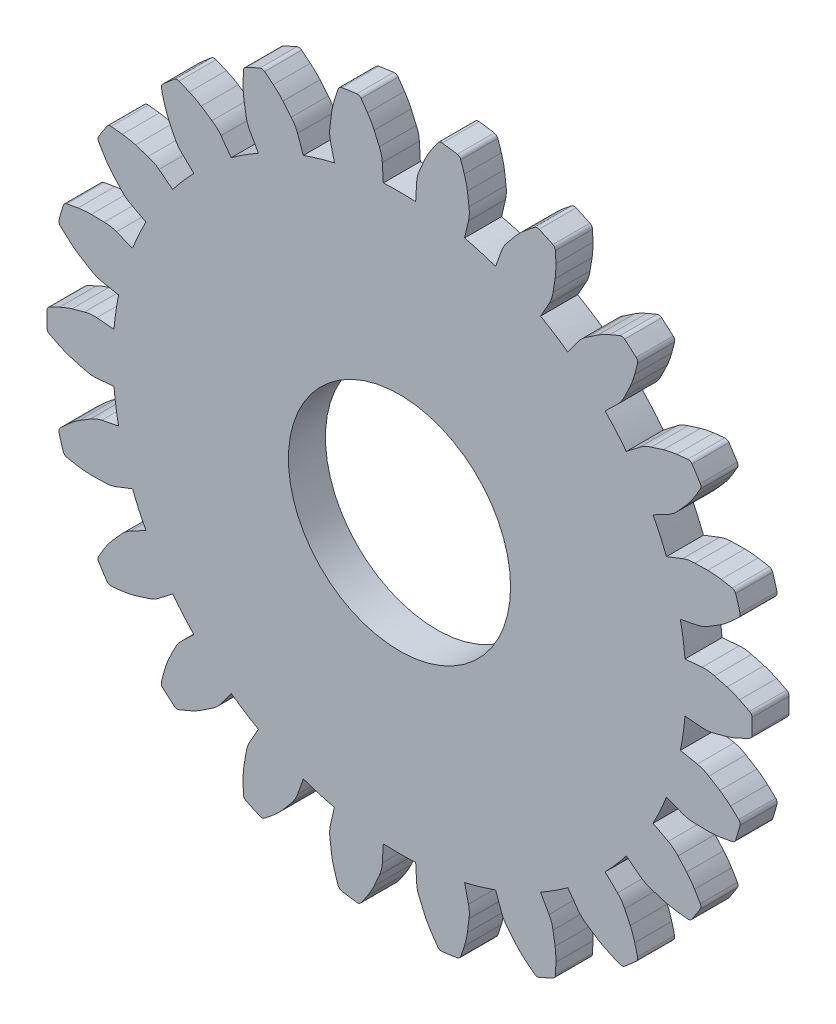
from build123d import *

# Parameters (mm, degrees)
MODEL_R             = 6
BOSS_EXTRUDE1_DEPTH = 2


with BuildPart() as part:
    # Model → Boss-Extrude1 (new body)
    with BuildSketch(Plane.XY):
        with BuildLine():
            Line((38.30992667, 23.504889052), (39.237718015, 23.585160756))
            ThreePointArc((39.237718015, 23.585160756), (39.575191224, 23.582048709), (39.905936677, 23.514927199))
            ThreePointArc((39.905936677, 23.514927199), (40.243502274, 23.423304664), (40.581052968, 23.331627241))
            ThreePointArc((40.581052968, 23.331627241), (40.924312438, 23.212321267), (41.257400116, 23.067016148))
            ThreePointArc((41.257400116, 23.067016148), (41.528774658, 22.934370847), (41.798724995, 22.798850613))
            ThreePointArc((41.798724995, 22.798850613), (41.896818886, 22.70924055), (41.934970041, 22.581973648))
            ThreePointArc((41.934970041, 22.581973648), (41.938299731, 22.376358445), (41.93940967, 22.170719278))
            ThreePointArc((41.93940967, 22.170719278), (41.938299731, 21.965080111), (41.934970041, 21.759464907))
            ThreePointArc((41.934970041, 21.759464907), (41.896818886, 21.632198005), (41.798724995, 21.542587942))
            ThreePointArc((41.798724995, 21.542587942), (41.528774658, 21.407067708), (41.257400116, 21.274422407))
            ThreePointArc((41.257400116, 21.274422407), (40.924312438, 21.129117288), (40.581052968, 21.009811315))
            ThreePointArc((40.581052968, 21.009811315), (40.243502274, 20.918133892), (39.905936677, 20.826511357))
            ThreePointArc((39.905936677, 20.826511357), (39.575191224, 20.759389846), (39.237718015, 20.756277799))
            Line((39.237718015, 20.756277799), (38.30992667, 20.836549503))
            ThreePointArc((38.30992667, 20.836549503), (38.266092553, 20.401545167), (38.209989675, 19.967952421))
            ThreePointArc((38.209989675, 19.967952421), (38.141662799, 19.536117221), (38.061166442, 19.10638412))
            Line((38.061166442, 19.10638412), (38.973990872, 18.922015227))
            ThreePointArc((38.973990872, 18.922015227), (39.29691728, 18.82395205), (39.595354903, 18.666367671))
            ThreePointArc((39.595354903, 18.666367671), (39.89343367, 18.483353273), (40.191482675, 18.30029041))
            ThreePointArc((40.191482675, 18.30029041), (40.487225347, 18.089109799), (40.765883452, 17.855848915))
            ThreePointArc((40.765883452, 17.855848915), (40.988894918, 17.652121637), (41.209729907, 17.446037126))
            ThreePointArc((41.209729907, 17.446037126), (41.278604235, 17.332420657), (41.27935477, 17.199560537))
            ThreePointArc((41.27935477, 17.199560537), (41.224621087, 17.001336112), (41.167750818, 16.80371407))
            ThreePointArc((41.167750818, 16.80371407), (41.10875059, 16.60671744), (41.047627279, 16.410369179))
            ThreePointArc((41.047627279, 16.410369179), (40.975166285, 16.299005903), (40.855799813, 16.24066192))
            ThreePointArc((40.855799813, 16.24066192), (40.5586039, 16.186685006), (40.260851433, 16.135867815))
            ThreePointArc((40.260851433, 16.135867815), (39.900318964, 16.090290218), (39.537351537, 16.072524343))
            ThreePointArc((39.537351537, 16.072524343), (39.187645504, 16.07965952), (38.837940634, 16.08685156))
            ThreePointArc((38.837940634, 16.08685156), (38.501682381, 16.115630705), (38.177002443, 16.207721908))
            Line((38.177002443, 16.207721908), (37.309408319, 16.546131071))
            ThreePointArc((37.309408319, 16.546131071), (37.144794908, 16.141096965), (36.968807398, 15.74087378))
            ThreePointArc((36.968807398, 15.74087378), (36.781586206, 15.345780845), (36.583280712, 14.956133398))
            Line((36.583280712, 14.956133398), (37.407186618, 14.52206038))
            ThreePointArc((37.407186618, 14.52206038), (37.689404648, 14.336990568), (37.931356801, 14.101709869))
            ThreePointArc((37.931356801, 14.101709869), (38.165800169, 13.842130347), (38.400201326, 13.582512708))
            ThreePointArc((38.400201326, 13.582512708), (38.624467889, 13.296566056), (38.826121197, 12.994246817))
            ThreePointArc((38.826121197, 12.994246817), (38.982702525, 12.735942334), (39.136531429, 12.475989288))
            ThreePointArc((39.136531429, 12.475989288), (39.170606404, 12.347570944), (39.133895516, 12.219881142))
            ThreePointArc((39.133895516, 12.219881142), (39.025532657, 12.045106459), (38.915289471, 11.871511705))
            ThreePointArc((38.915289471, 11.871511705), (38.803178803, 11.699117108), (38.689213718, 11.527942757))
            ThreePointArc((38.689213718, 11.527942757), (38.588313242, 11.441505098), (38.457344552, 11.419153878))
            ThreePointArc((38.457344552, 11.419153878), (38.156980107, 11.451093173), (37.856971851, 11.486220999))
            ThreePointArc((37.856971851, 11.486220999), (37.498202787, 11.544063349), (37.144932866, 11.629276858))
            ThreePointArc((37.144932866, 11.629276858), (36.811402595, 11.734646585), (36.477889462, 11.840070544))
            ThreePointArc((36.477889462, 11.840070544), (36.163360053, 11.962418828), (35.877777024, 12.142252599))
            Line((35.877777024, 12.142252599), (35.140667436, 12.711383325))
            ThreePointArc((35.140667436, 12.711383325), (34.868610731, 12.369132903), (34.586996051, 12.03470298))
            ThreePointArc((34.586996051, 12.03470298), (34.296048089, 11.70836039), (33.995998989, 11.390365517))
            Line((33.995998989, 11.390365517), (34.664238417, 10.741754389))
            ThreePointArc((34.664238417, 10.741754389), (34.882884442, 10.484671197), (35.048749599, 10.190755221))
            ThreePointArc((35.048749599, 10.190755221), (35.200564362, 9.875640164), (35.352327884, 9.560500426))
            ThreePointArc((35.352327884, 9.560500426), (35.486949594, 9.222953431), (35.595261353, 8.876067943))
            ThreePointArc((35.595261353, 8.876067943), (35.672727255, 8.584112549), (35.747087772, 8.291350817))
            ThreePointArc((35.747087772, 8.291350817), (35.743602842, 8.158534289), (35.672404629, 8.046359473))
            ThreePointArc((35.672404629, 8.046359473), (35.519191509, 7.909193738), (35.364506652, 7.773689886))
            ThreePointArc((35.364506652, 7.773689886), (35.208368083, 7.639863707), (35.050793997, 7.507730795))
            ThreePointArc((35.050793997, 7.507730795), (34.929628397, 7.453221417), (34.797667793, 7.468673722))
            ThreePointArc((34.797667793, 7.468673722), (34.518468558, 7.583941694), (34.240509396, 7.70216869))
            ThreePointArc((34.240509396, 7.70216869), (33.912569073, 7.858744944), (33.597616486, 8.040034345))
            ThreePointArc((33.597616486, 8.040034345), (33.307282617, 8.235102194), (33.016980471, 8.430217249))
            ThreePointArc((33.016980471, 8.430217249), (32.749661208, 8.636222743), (32.526311327, 8.88923002))
            Line((32.526311327, 8.88923002), (31.979402511, 9.642974721))
            ThreePointArc((31.979402511, 9.642974721), (31.621942928, 9.391235077), (31.257515823, 9.14969194))
            ThreePointArc((31.257515823, 9.14969194), (30.886411966, 8.918538031), (30.508927454, 8.697957784))
            Line((30.508927454, 8.697957784), (30.967363618, 7.887355162))
            ThreePointArc((30.967363618, 7.887355162), (31.104724238, 7.579085942), (31.181064992, 7.250346013))
            ThreePointArc((31.181064992, 7.250346013), (31.237952019, 6.905224169), (31.294782928, 6.56009308))
            ThreePointArc((31.294782928, 6.56009308), (31.328853534, 6.198291791), (31.335048971, 5.834942654))
            ThreePointArc((31.335048971, 5.834942654), (31.32712362, 5.532988838), (31.315991502, 5.231136235))
            ThreePointArc((31.315991502, 5.231136235), (31.275228996, 5.104681527), (31.175311513, 5.017109435))
            ThreePointArc((31.175311513, 5.017109435), (30.989660548, 4.928665), (30.803065668, 4.842229766))
            ThreePointArc((30.803065668, 4.842229766), (30.615548617, 4.757813806), (30.427131245, 4.675426955))
            ThreePointArc((30.427131245, 4.675426955), (30.295516637, 4.657261884), (30.173254782, 4.709265861))
            ThreePointArc((30.173254782, 4.709265861), (29.937839818, 4.898524185), (29.704448349, 5.090272301))
            ThreePointArc((29.704448349, 5.090272301), (29.433904542, 5.332897583), (29.182784874, 5.595575887))
            ThreePointArc((29.182784874, 5.595575887), (28.959168531, 5.86453862), (28.735595925, 6.133537711))
            ThreePointArc((28.735595925, 6.133537711), (28.537143425, 6.406511074), (28.39412117, 6.712194712))
            Line((28.39412117, 6.712194712), (28.081720426, 7.589489476))
            ThreePointArc((28.081720426, 7.589489476), (27.667817214, 7.448655059), (27.250101402, 7.319567095))
            ThreePointArc((27.250101402, 7.319567095), (26.828906277, 7.202328582), (26.404567903, 7.097033062))
            Line((26.404567903, 7.097033062), (26.616061032, 6.19010915))
            ThreePointArc((26.616061032, 6.19010915), (26.661008106, 5.85562804), (26.641639782, 5.518696712))
            ThreePointArc((26.641639782, 5.518696712), (26.598990425, 5.171527801), (26.556284619, 4.824365828))
            ThreePointArc((26.556284619, 4.824365828), (26.487043924, 4.467621235), (26.390621121, 4.117244834))
            ThreePointArc((26.390621121, 4.117244834), (26.297946582, 3.829755099), (26.202223687, 3.543265927))
            ThreePointArc((26.202223687, 3.543265927), (26.127485941, 3.433417649), (26.006943908, 3.377542849))
            ThreePointArc((26.006943908, 3.377542849), (25.803895435, 3.344984957), (25.600507339, 3.31462081))
            ThreePointArc((25.600507339, 3.31462081), (25.396803322, 3.286453947), (25.19280712, 3.260487651))
            ThreePointArc((25.19280712, 3.260487651), (25.061406136, 3.280138513), (24.958747958, 3.364481108))
            ThreePointArc((24.958747958, 3.364481108), (24.786189186, 3.6123972), (24.616273399, 3.862132146))
            ThreePointArc((24.616273399, 3.862132146), (24.425043957, 4.171150397), (24.258101431, 4.49393697))
            ThreePointArc((24.258101431, 4.49393697), (24.11931868, 4.815004827), (23.980588137, 5.136095247))
            ThreePointArc((23.980588137, 5.136095247), (23.867079841, 5.453921801), (23.815972025, 5.787517129))
            Line((23.815972025, 5.787517129), (23.763388203, 6.717288751))
            ThreePointArc((23.763388203, 6.717288751), (23.326573339, 6.698769128), (22.88940967, 6.692594278))
            ThreePointArc((22.88940967, 6.692594278), (22.452246001, 6.698769128), (22.015431137, 6.717288751))
            Line((22.015431137, 6.717288751), (21.962847315, 5.787517129))
            ThreePointArc((21.962847315, 5.787517129), (21.911739499, 5.453921801), (21.798231204, 5.136095247))
            ThreePointArc((21.798231204, 5.136095247), (21.659500661, 4.815004827), (21.520717909, 4.49393697))
            ThreePointArc((21.520717909, 4.49393697), (21.353775383, 4.171150397), (21.162545942, 3.862132146))
            ThreePointArc((21.162545942, 3.862132146), (20.992630154, 3.6123972), (20.820071382, 3.364481108))
            ThreePointArc((20.820071382, 3.364481108), (20.717413204, 3.280138513), (20.58601222, 3.260487651))
            ThreePointArc((20.58601222, 3.260487651), (20.382016019, 3.286453947), (20.178312001, 3.31462081))
            ThreePointArc((20.178312001, 3.31462081), (19.974923905, 3.344984957), (19.771875432, 3.377542849))
            ThreePointArc((19.771875432, 3.377542849), (19.651333399, 3.433417649), (19.576595654, 3.543265927))
            ThreePointArc((19.576595654, 3.543265927), (19.480872759, 3.829755099), (19.388198219, 4.117244834))
            ThreePointArc((19.388198219, 4.117244834), (19.291775416, 4.467621235), (19.222534722, 4.824365828))
            ThreePointArc((19.222534722, 4.824365828), (19.179828915, 5.171527801), (19.137179558, 5.518696712))
            ThreePointArc((19.137179558, 5.518696712), (19.117811234, 5.85562804), (19.162758309, 6.19010915))
            Line((19.162758309, 6.19010915), (19.374251437, 7.097033062))
            ThreePointArc((19.374251437, 7.097033062), (18.949913064, 7.202328582), (18.528717939, 7.319567095))
            ThreePointArc((18.528717939, 7.319567095), (18.111002127, 7.448655059), (17.697098915, 7.589489476))
            Line((17.697098915, 7.589489476), (17.384698171, 6.712194712))
            ThreePointArc((17.384698171, 6.712194712), (17.241675916, 6.406511074), (17.043223416, 6.133537711))
            ThreePointArc((17.043223416, 6.133537711), (16.819650809, 5.86453862), (16.596034466, 5.595575887))
            ThreePointArc((16.596034466, 5.595575887), (16.344914799, 5.332897583), (16.074370991, 5.090272301))
            ThreePointArc((16.074370991, 5.090272301), (15.840979522, 4.898524185), (15.605564559, 4.709265861))
            ThreePointArc((15.605564559, 4.709265861), (15.483302703, 4.657261884), (15.351688095, 4.675426955))
            ThreePointArc((15.351688095, 4.675426955), (15.163270724, 4.757813806), (14.975753672, 4.842229766))
            ThreePointArc((14.975753672, 4.842229766), (14.789158792, 4.928665), (14.603507827, 5.017109435))
            ThreePointArc((14.603507827, 5.017109435), (14.503590344, 5.104681527), (14.462827838, 5.231136235))
            ThreePointArc((14.462827838, 5.231136235), (14.45169572, 5.532988838), (14.443770369, 5.834942654))
            ThreePointArc((14.443770369, 5.834942654), (14.449965806, 6.198291791), (14.484036413, 6.56009308))
            ThreePointArc((14.484036413, 6.56009308), (14.540867322, 6.905224169), (14.597754349, 7.250346013))
            ThreePointArc((14.597754349, 7.250346013), (14.674095102, 7.579085942), (14.811455722, 7.887355162))
            Line((14.811455722, 7.887355162), (15.269891886, 8.697957784))
            ThreePointArc((15.269891886, 8.697957784), (14.892407374, 8.918538031), (14.521303517, 9.14969194))
            ThreePointArc((14.521303517, 9.14969194), (14.156876413, 9.391235077), (13.799416829, 9.642974721))
            Line((13.799416829, 9.642974721), (13.252508014, 8.88923002))
            ThreePointArc((13.252508014, 8.88923002), (13.029158132, 8.636222743), (12.761838869, 8.430217249))
            ThreePointArc((12.761838869, 8.430217249), (12.471536723, 8.235102194), (12.181202854, 8.040034345))
            ThreePointArc((12.181202854, 8.040034345), (11.866250267, 7.858744944), (11.538309944, 7.70216869))
            ThreePointArc((11.538309944, 7.70216869), (11.260350782, 7.583941694), (10.981151548, 7.468673722))
            ThreePointArc((10.981151548, 7.468673722), (10.849190943, 7.453221417), (10.728025343, 7.507730795))
            ThreePointArc((10.728025343, 7.507730795), (10.570451257, 7.639863707), (10.414312688, 7.773689886))
            ThreePointArc((10.414312688, 7.773689886), (10.259627832, 7.909193738), (10.106414712, 8.046359473))
            ThreePointArc((10.106414712, 8.046359473), (10.035216498, 8.158534289), (10.031731569, 8.291350817))
            ThreePointArc((10.031731569, 8.291350817), (10.106092085, 8.584112549), (10.183557987, 8.876067943))
            ThreePointArc((10.183557987, 8.876067943), (10.291869747, 9.222953431), (10.426491456, 9.560500426))
            ThreePointArc((10.426491456, 9.560500426), (10.578254978, 9.875640164), (10.730069741, 10.190755221))
            ThreePointArc((10.730069741, 10.190755221), (10.895934898, 10.484671197), (11.114580924, 10.741754389))
            Line((11.114580924, 10.741754389), (11.782820351, 11.390365517))
            ThreePointArc((11.782820351, 11.390365517), (11.482771251, 11.70836039), (11.19182329, 12.03470298))
            ThreePointArc((11.19182329, 12.03470298), (10.910208609, 12.369132903), (10.638151904, 12.711383325))
            Line((10.638151904, 12.711383325), (9.901042316, 12.142252599))
            ThreePointArc((9.901042316, 12.142252599), (9.615459287, 11.962418828), (9.300929878, 11.840070544))
            ThreePointArc((9.300929878, 11.840070544), (8.967416745, 11.734646585), (8.633886474, 11.629276858))
            ThreePointArc((8.633886474, 11.629276858), (8.280616554, 11.544063349), (7.921847489, 11.486220999))
            ThreePointArc((7.921847489, 11.486220999), (7.621839233, 11.451093173), (7.321474788, 11.419153878))
            ThreePointArc((7.321474788, 11.419153878), (7.190506098, 11.441505098), (7.089605623, 11.527942757))
            ThreePointArc((7.089605623, 11.527942757), (6.975640538, 11.699117108), (6.86352987, 11.871511705))
            ThreePointArc((6.86352987, 11.871511705), (6.753286683, 12.045106459), (6.644923824, 12.219881142))
            ThreePointArc((6.644923824, 12.219881142), (6.608212936, 12.347570944), (6.642287911, 12.475989288))
            ThreePointArc((6.642287911, 12.475989288), (6.796116815, 12.735942334), (6.952698144, 12.994246817))
            ThreePointArc((6.952698144, 12.994246817), (7.154351451, 13.296566056), (7.378618014, 13.582512708))
            ThreePointArc((7.378618014, 13.582512708), (7.613019171, 13.842130347), (7.84746254, 14.101709869))
            ThreePointArc((7.84746254, 14.101709869), (8.089414692, 14.336990568), (8.371632722, 14.52206038))
            Line((8.371632722, 14.52206038), (9.195538629, 14.956133398))
            ThreePointArc((9.195538629, 14.956133398), (8.997233134, 15.345780845), (8.810011942, 15.74087378))
            ThreePointArc((8.810011942, 15.74087378), (8.634024432, 16.141096965), (8.469411022, 16.546131071))
            Line((8.469411022, 16.546131071), (7.601816897, 16.207721908))
            ThreePointArc((7.601816897, 16.207721908), (7.277136959, 16.115630705), (6.940878706, 16.08685156))
            ThreePointArc((6.940878706, 16.08685156), (6.591173837, 16.07965952), (6.241467803, 16.072524343))
            ThreePointArc((6.241467803, 16.072524343), (5.878500376, 16.090290218), (5.517967907, 16.135867815))
            ThreePointArc((5.517967907, 16.135867815), (5.220215441, 16.186685006), (4.923019527, 16.24066192))
            ThreePointArc((4.923019527, 16.24066192), (4.803653056, 16.299005903), (4.731192061, 16.410369179))
            ThreePointArc((4.731192061, 16.410369179), (4.67006875, 16.60671744), (4.611068523, 16.80371407))
            ThreePointArc((4.611068523, 16.80371407), (4.554198254, 17.001336112), (4.49946457, 17.199560537))
            ThreePointArc((4.49946457, 17.199560537), (4.500215106, 17.332420657), (4.569089433, 17.446037126))
            ThreePointArc((4.569089433, 17.446037126), (4.789924422, 17.652121637), (5.012935889, 17.855848915))
            ThreePointArc((5.012935889, 17.855848915), (5.291593993, 18.089109799), (5.587336665, 18.30029041))
            ThreePointArc((5.587336665, 18.30029041), (5.88538567, 18.483353273), (6.183464437, 18.666367671))
            ThreePointArc((6.183464437, 18.666367671), (6.48190206, 18.82395205), (6.804828469, 18.922015227))
            Line((6.804828469, 18.922015227), (7.717652898, 19.10638412))
            ThreePointArc((7.717652898, 19.10638412), (7.637156541, 19.536117221), (7.568829665, 19.967952421))
            ThreePointArc((7.568829665, 19.967952421), (7.512726787, 20.401545167), (7.468892671, 20.836549503))
            Line((7.468892671, 20.836549503), (6.541101325, 20.756277799))
            ThreePointArc((6.541101325, 20.756277799), (6.203628116, 20.759389846), (5.872882663, 20.826511357))
            ThreePointArc((5.872882663, 20.826511357), (5.535317066, 20.918133892), (5.197766372, 21.009811315))
            ThreePointArc((5.197766372, 21.009811315), (4.854506902, 21.129117288), (4.521419224, 21.274422407))
            ThreePointArc((4.521419224, 21.274422407), (4.250044682, 21.407067708), (3.980094345, 21.542587942))
            ThreePointArc((3.980094345, 21.542587942), (3.882000454, 21.632198005), (3.843849299, 21.759464907))
            ThreePointArc((3.843849299, 21.759464907), (3.84051961, 21.965080111), (3.83940967, 22.170719278))
            ThreePointArc((3.83940967, 22.170719278), (3.84051961, 22.376358445), (3.843849299, 22.581973648))
            ThreePointArc((3.843849299, 22.581973648), (3.882000454, 22.70924055), (3.980094345, 22.798850613))
            ThreePointArc((3.980094345, 22.798850613), (4.250044682, 22.934370847), (4.521419224, 23.067016148))
            ThreePointArc((4.521419224, 23.067016148), (4.854506902, 23.212321267), (5.197766372, 23.331627241))
            ThreePointArc((5.197766372, 23.331627241), (5.535317066, 23.423304664), (5.872882663, 23.514927199))
            ThreePointArc((5.872882663, 23.514927199), (6.203628116, 23.582048709), (6.541101325, 23.585160756))
            Line((6.541101325, 23.585160756), (7.468892671, 23.504889052))
            ThreePointArc((7.468892671, 23.504889052), (7.512726787, 23.939893388), (7.568829665, 24.373486134))
            ThreePointArc((7.568829665, 24.373486134), (7.637156541, 24.805321334), (7.717652898, 25.235054435))
            Line((7.717652898, 25.235054435), (6.804828469, 25.419423328))
            ThreePointArc((6.804828469, 25.419423328), (6.48190206, 25.517486505), (6.183464437, 25.675070885))
            ThreePointArc((6.183464437, 25.675070885), (5.88538567, 25.858085282), (5.587336665, 26.041148145))
            ThreePointArc((5.587336665, 26.041148145), (5.291593993, 26.252328756), (5.012935889, 26.48558964))
            ThreePointArc((5.012935889, 26.48558964), (4.789924422, 26.689316918), (4.569089433, 26.895401429))
            ThreePointArc((4.569089433, 26.895401429), (4.500215106, 27.009017898), (4.49946457, 27.141878018))
            ThreePointArc((4.49946457, 27.141878018), (4.554198254, 27.340102444), (4.611068523, 27.537724485))
            ThreePointArc((4.611068523, 27.537724485), (4.67006875, 27.734721115), (4.731192061, 27.931069377))
            ThreePointArc((4.731192061, 27.931069377), (4.803653056, 28.042432652), (4.923019527, 28.100776635))
            ThreePointArc((4.923019527, 28.100776635), (5.220215441, 28.154753549), (5.517967907, 28.20557074))
            ThreePointArc((5.517967907, 28.20557074), (5.878500376, 28.251148337), (6.241467803, 28.268914212))
            ThreePointArc((6.241467803, 28.268914212), (6.591173837, 28.261779035), (6.940878706, 28.254586995))
            ThreePointArc((6.940878706, 28.254586995), (7.277136959, 28.225807851), (7.601816897, 28.133716648))
            Line((7.601816897, 28.133716648), (8.469411022, 27.795307484))
            ThreePointArc((8.469411022, 27.795307484), (8.634024432, 28.20034159), (8.810011942, 28.600564776))
            ThreePointArc((8.810011942, 28.600564776), (8.997233134, 28.995657711), (9.195538629, 29.385305158))
            Line((9.195538629, 29.385305158), (8.371632722, 29.819378175))
            ThreePointArc((8.371632722, 29.819378175), (8.089414692, 30.004447987), (7.84746254, 30.239728687))
            ThreePointArc((7.84746254, 30.239728687), (7.613019171, 30.499308208), (7.378618014, 30.758925847))
            ThreePointArc((7.378618014, 30.758925847), (7.154351451, 31.044872499), (6.952698144, 31.347191738))
            ThreePointArc((6.952698144, 31.347191738), (6.796116815, 31.605496221), (6.642287911, 31.865449267))
            ThreePointArc((6.642287911, 31.865449267), (6.608212936, 31.993867611), (6.644923824, 32.121557413))
            ThreePointArc((6.644923824, 32.121557413), (6.753286683, 32.296332096), (6.86352987, 32.46992685))
            ThreePointArc((6.86352987, 32.46992685), (6.975640538, 32.642321447), (7.089605623, 32.813495798))
            ThreePointArc((7.089605623, 32.813495798), (7.190506098, 32.899933457), (7.321474788, 32.922284678))
            ThreePointArc((7.321474788, 32.922284678), (7.621839233, 32.890345383), (7.921847489, 32.855217556))
            ThreePointArc((7.921847489, 32.855217556), (8.280616554, 32.797375206), (8.633886474, 32.712161698))
            ThreePointArc((8.633886474, 32.712161698), (8.967416745, 32.60679197), (9.300929878, 32.501368012))
            ThreePointArc((9.300929878, 32.501368012), (9.615459287, 32.379019727), (9.901042316, 32.199185956))
            Line((9.901042316, 32.199185956), (10.638151904, 31.63005523))
            ThreePointArc((10.638151904, 31.63005523), (10.910208609, 31.972305652), (11.19182329, 32.306735575))
            ThreePointArc((11.19182329, 32.306735575), (11.482771251, 32.633078165), (11.782820351, 32.951073038))
            Line((11.782820351, 32.951073038), (11.114580924, 33.599684166))
            ThreePointArc((11.114580924, 33.599684166), (10.895934898, 33.856767358), (10.730069741, 34.150683335))
            ThreePointArc((10.730069741, 34.150683335), (10.578254978, 34.465798391), (10.426491456, 34.780938129))
            ThreePointArc((10.426491456, 34.780938129), (10.291869747, 35.118485124), (10.183557987, 35.465370612))
            ThreePointArc((10.183557987, 35.465370612), (10.106092085, 35.757326006), (10.031731569, 36.050087738))
            ThreePointArc((10.031731569, 36.050087738), (10.035216498, 36.182904266), (10.106414712, 36.295079082))
            ThreePointArc((10.106414712, 36.295079082), (10.259627832, 36.432244817), (10.414312688, 36.567748669))
            ThreePointArc((10.414312688, 36.567748669), (10.570451257, 36.701574848), (10.728025343, 36.83370776))
            ThreePointArc((10.728025343, 36.83370776), (10.849190943, 36.888217138), (10.981151548, 36.872764833))
            ThreePointArc((10.981151548, 36.872764833), (11.260350782, 36.757496861), (11.538309944, 36.639269866))
            ThreePointArc((11.538309944, 36.639269866), (11.866250267, 36.482693611), (12.181202854, 36.30140421))
            ThreePointArc((12.181202854, 36.30140421), (12.471536723, 36.106336361), (12.761838869, 35.911221306))
            ThreePointArc((12.761838869, 35.911221306), (13.029158132, 35.705215812), (13.252508014, 35.452208535))
            Line((13.252508014, 35.452208535), (13.799416829, 34.698463834))
            ThreePointArc((13.799416829, 34.698463834), (14.156876413, 34.950203478), (14.521303517, 35.191746615))
            ThreePointArc((14.521303517, 35.191746615), (14.892407374, 35.422900524), (15.269891886, 35.643480771))
            Line((15.269891886, 35.643480771), (14.811455722, 36.454083393))
            ThreePointArc((14.811455722, 36.454083393), (14.674095102, 36.762352613), (14.597754349, 37.091092542))
            ThreePointArc((14.597754349, 37.091092542), (14.540867322, 37.436214386), (14.484036413, 37.781345475))
            ThreePointArc((14.484036413, 37.781345475), (14.449965806, 38.143146764), (14.443770369, 38.506495901))
            ThreePointArc((14.443770369, 38.506495901), (14.45169572, 38.808449717), (14.462827838, 39.11030232))
            ThreePointArc((14.462827838, 39.11030232), (14.503590344, 39.236757028), (14.603507827, 39.324329121))
            ThreePointArc((14.603507827, 39.324329121), (14.789158792, 39.412773555), (14.975753672, 39.499208789))
            ThreePointArc((14.975753672, 39.499208789), (15.163270724, 39.58362475), (15.351688095, 39.6660116))
            ThreePointArc((15.351688095, 39.6660116), (15.483302703, 39.684176671), (15.605564559, 39.632172694))
            ThreePointArc((15.605564559, 39.632172694), (15.840979522, 39.442914371), (16.074370991, 39.251166254))
            ThreePointArc((16.074370991, 39.251166254), (16.344914799, 39.008540972), (16.596034466, 38.745862668))
            ThreePointArc((16.596034466, 38.745862668), (16.819650809, 38.476899935), (17.043223416, 38.207900844))
            ThreePointArc((17.043223416, 38.207900844), (17.241675916, 37.934927481), (17.384698171, 37.629243843))
            Line((17.384698171, 37.629243843), (17.697098915, 36.751949079))
            ThreePointArc((17.697098915, 36.751949079), (18.111002127, 36.892783496), (18.528717939, 37.02187146))
            ThreePointArc((18.528717939, 37.02187146), (18.949913064, 37.139109973), (19.374251437, 37.244405493))
            Line((19.374251437, 37.244405493), (19.162758309, 38.151329406))
            ThreePointArc((19.162758309, 38.151329406), (19.117811234, 38.485810515), (19.137179558, 38.822741843))
            ThreePointArc((19.137179558, 38.822741843), (19.179828915, 39.169910755), (19.222534722, 39.517072727))
            ThreePointArc((19.222534722, 39.517072727), (19.291775416, 39.873817321), (19.388198219, 40.224193721))
            ThreePointArc((19.388198219, 40.224193721), (19.480872759, 40.511683456), (19.576595654, 40.798172628))
            ThreePointArc((19.576595654, 40.798172628), (19.651333399, 40.908020907), (19.771875432, 40.963895706))
            ThreePointArc((19.771875432, 40.963895706), (19.974923905, 40.996453599), (20.178312001, 41.026817745))
            ThreePointArc((20.178312001, 41.026817745), (20.382016019, 41.054984608), (20.58601222, 41.080950905))
            ThreePointArc((20.58601222, 41.080950905), (20.717413204, 41.061300042), (20.820071382, 40.976957447))
            ThreePointArc((20.820071382, 40.976957447), (20.992630154, 40.729041356), (21.162545941, 40.47930641))
            ThreePointArc((21.162545941, 40.47930641), (21.353775383, 40.170288158), (21.520717909, 39.847501585))
            ThreePointArc((21.520717909, 39.847501585), (21.659500661, 39.526433728), (21.798231204, 39.205343309))
            ThreePointArc((21.798231204, 39.205343309), (21.911739499, 38.887516754), (21.962847315, 38.553921426))
            Line((21.962847315, 38.553921426), (22.015431137, 37.624149804))
            ThreePointArc((22.015431137, 37.624149804), (22.452246001, 37.642669428), (22.88940967, 37.648844278))
            ThreePointArc((22.88940967, 37.648844278), (23.326573339, 37.642669428), (23.763388203, 37.624149804))
            Line((23.763388203, 37.624149804), (23.815972025, 38.553921426))
            ThreePointArc((23.815972025, 38.553921426), (23.867079841, 38.887516754), (23.980588137, 39.205343309))
            ThreePointArc((23.980588137, 39.205343309), (24.11931868, 39.526433728), (24.258101431, 39.847501585))
            ThreePointArc((24.258101431, 39.847501585), (24.425043957, 40.170288158), (24.616273399, 40.47930641))
            ThreePointArc((24.616273399, 40.47930641), (24.786189186, 40.729041356), (24.958747958, 40.976957447))
            ThreePointArc((24.958747958, 40.976957447), (25.061406136, 41.061300042), (25.19280712, 41.080950905))
            ThreePointArc((25.19280712, 41.080950905), (25.396803322, 41.054984608), (25.600507339, 41.026817745))
            ThreePointArc((25.600507339, 41.026817745), (25.803895435, 40.996453599), (26.006943908, 40.963895706))
            ThreePointArc((26.006943908, 40.963895706), (26.127485941, 40.908020907), (26.202223687, 40.798172628))
            ThreePointArc((26.202223687, 40.798172628), (26.297946582, 40.511683456), (26.390621121, 40.224193721))
            ThreePointArc((26.390621121, 40.224193721), (26.487043924, 39.873817321), (26.556284619, 39.517072727))
            ThreePointArc((26.556284619, 39.517072727), (26.598990425, 39.169910755), (26.641639782, 38.822741843))
            ThreePointArc((26.641639782, 38.822741843), (26.661008106, 38.485810515), (26.616061032, 38.151329406))
            Line((26.616061032, 38.151329406), (26.404567903, 37.244405493))
            ThreePointArc((26.404567903, 37.244405493), (26.828906277, 37.139109973), (27.250101402, 37.02187146))
            ThreePointArc((27.250101402, 37.02187146), (27.667817214, 36.892783496), (28.081720426, 36.751949079))
            Line((28.081720426, 36.751949079), (28.39412117, 37.629243843))
            ThreePointArc((28.39412117, 37.629243843), (28.537143425, 37.934927481), (28.735595925, 38.207900844))
            ThreePointArc((28.735595925, 38.207900844), (28.959168531, 38.476899935), (29.182784874, 38.745862668))
            ThreePointArc((29.182784874, 38.745862668), (29.433904542, 39.008540972), (29.704448349, 39.251166254))
            ThreePointArc((29.704448349, 39.251166254), (29.937839818, 39.442914371), (30.173254782, 39.632172694))
            ThreePointArc((30.173254782, 39.632172694), (30.295516637, 39.684176671), (30.427131245, 39.6660116))
            ThreePointArc((30.427131245, 39.6660116), (30.615548617, 39.58362475), (30.803065668, 39.499208789))
            ThreePointArc((30.803065668, 39.499208789), (30.989660548, 39.412773555), (31.175311513, 39.324329121))
            ThreePointArc((31.175311513, 39.324329121), (31.275228996, 39.236757028), (31.315991502, 39.11030232))
            ThreePointArc((31.315991502, 39.11030232), (31.32712362, 38.808449717), (31.335048971, 38.506495901))
            ThreePointArc((31.335048971, 38.506495901), (31.328853534, 38.143146764), (31.294782928, 37.781345475))
            ThreePointArc((31.294782928, 37.781345475), (31.237952019, 37.436214386), (31.181064992, 37.091092542))
            ThreePointArc((31.181064992, 37.091092542), (31.104724238, 36.762352613), (30.967363618, 36.454083393))
            Line((30.967363618, 36.454083393), (30.508927454, 35.643480771))
            ThreePointArc((30.508927454, 35.643480771), (30.886411966, 35.422900524), (31.257515823, 35.191746615))
            ThreePointArc((31.257515823, 35.191746615), (31.621942928, 34.950203478), (31.979402511, 34.698463834))
            Line((31.979402511, 34.698463834), (32.526311327, 35.452208535))
            ThreePointArc((32.526311327, 35.452208535), (32.749661208, 35.705215812), (33.016980471, 35.911221306))
            ThreePointArc((33.016980471, 35.911221306), (33.307282617, 36.106336361), (33.597616486, 36.30140421))
            ThreePointArc((33.597616486, 36.30140421), (33.912569073, 36.482693611), (34.240509396, 36.639269866))
            ThreePointArc((34.240509396, 36.639269866), (34.518468558, 36.757496861), (34.797667793, 36.872764833))
            ThreePointArc((34.797667793, 36.872764833), (34.929628397, 36.888217138), (35.050793997, 36.83370776))
            ThreePointArc((35.050793997, 36.83370776), (35.208368083, 36.701574848), (35.364506652, 36.567748669))
            ThreePointArc((35.364506652, 36.567748669), (35.519191509, 36.432244817), (35.672404629, 36.295079082))
            ThreePointArc((35.672404629, 36.295079082), (35.743602842, 36.182904266), (35.747087772, 36.050087738))
            ThreePointArc((35.747087772, 36.050087738), (35.672727255, 35.757326006), (35.595261353, 35.465370612))
            ThreePointArc((35.595261353, 35.465370612), (35.486949594, 35.118485124), (35.352327884, 34.780938129))
            ThreePointArc((35.352327884, 34.780938129), (35.200564362, 34.465798391), (35.0487496, 34.150683335))
            ThreePointArc((35.0487496, 34.150683335), (34.882884442, 33.856767358), (34.664238417, 33.599684166))
            Line((34.664238417, 33.599684166), (33.995998989, 32.951073038))
            ThreePointArc((33.995998989, 32.951073038), (34.296048089, 32.633078165), (34.586996051, 32.306735575))
            ThreePointArc((34.586996051, 32.306735575), (34.868610731, 31.972305652), (35.140667436, 31.63005523))
            Line((35.140667436, 31.63005523), (35.877777024, 32.199185956))
            ThreePointArc((35.877777024, 32.199185956), (36.163360053, 32.379019727), (36.477889462, 32.501368012))
            ThreePointArc((36.477889462, 32.501368012), (36.811402595, 32.60679197), (37.144932866, 32.712161698))
            ThreePointArc((37.144932866, 32.712161698), (37.498202787, 32.797375206), (37.856971851, 32.855217556))
            ThreePointArc((37.856971851, 32.855217556), (38.156980107, 32.890345383), (38.457344552, 32.922284678))
            ThreePointArc((38.457344552, 32.922284678), (38.588313242, 32.899933457), (38.689213718, 32.813495798))
            ThreePointArc((38.689213718, 32.813495798), (38.803178803, 32.642321447), (38.915289471, 32.46992685))
            ThreePointArc((38.915289471, 32.46992685), (39.025532657, 32.296332096), (39.133895516, 32.121557413))
            ThreePointArc((39.133895516, 32.121557413), (39.170606404, 31.993867611), (39.136531429, 31.865449267))
            ThreePointArc((39.136531429, 31.865449267), (38.982702525, 31.605496221), (38.826121197, 31.347191738))
            ThreePointArc((38.826121197, 31.347191738), (38.624467889, 31.044872499), (38.400201326, 30.758925847))
            ThreePointArc((38.400201326, 30.758925847), (38.165800169, 30.499308208), (37.931356801, 30.239728687))
            ThreePointArc((37.931356801, 30.239728687), (37.689404648, 30.004447987), (37.407186618, 29.819378175))
            Line((37.407186618, 29.819378175), (36.583280712, 29.385305158))
            ThreePointArc((36.583280712, 29.385305158), (36.781586206, 28.995657711), (36.968807398, 28.600564776))
            ThreePointArc((36.968807398, 28.600564776), (37.144794908, 28.20034159), (37.309408319, 27.795307484))
            Line((37.309408319, 27.795307484), (38.177002443, 28.133716648))
            ThreePointArc((38.177002443, 28.133716648), (38.501682381, 28.225807851), (38.837940634, 28.254586995))
            ThreePointArc((38.837940634, 28.254586995), (39.187645504, 28.261779035), (39.537351537, 28.268914212))
            ThreePointArc((39.537351537, 28.268914212), (39.900318964, 28.251148337), (40.260851433, 28.20557074))
            ThreePointArc((40.260851433, 28.20557074), (40.5586039, 28.154753549), (40.855799813, 28.100776635))
            ThreePointArc((40.855799813, 28.100776635), (40.975166285, 28.042432652), (41.047627279, 27.931069377))
            ThreePointArc((41.047627279, 27.931069377), (41.10875059, 27.734721115), (41.167750818, 27.537724485))
            ThreePointArc((41.167750818, 27.537724485), (41.224621087, 27.340102444), (41.27935477, 27.141878018))
            ThreePointArc((41.27935477, 27.141878018), (41.278604235, 27.009017898), (41.209729907, 26.895401429))
            ThreePointArc((41.209729907, 26.895401429), (40.988894918, 26.689316918), (40.765883452, 26.48558964))
            ThreePointArc((40.765883452, 26.48558964), (40.487225347, 26.252328756), (40.191482675, 26.041148145))
            ThreePointArc((40.191482675, 26.041148145), (39.89343367, 25.858085282), (39.595354903, 25.675070885))
            ThreePointArc((39.595354903, 25.675070885), (39.29691728, 25.517486505), (38.973990872, 25.419423328))
            Line((38.973990872, 25.419423328), (38.061166442, 25.235054435))
            ThreePointArc((38.061166442, 25.235054435), (38.141662799, 24.805321334), (38.209989675, 24.373486134))
            ThreePointArc((38.209989675, 24.373486134), (38.266092553, 23.939893388), (38.30992667, 23.504889052))
        make_face()
        with Locations((22.88940967, 22.170719278)):
            Circle(MODEL_R, mode=Mode.SUBTRACT)
    extrude(amount=BOSS_EXTRUDE1_DEPTH)


solid = part.part
